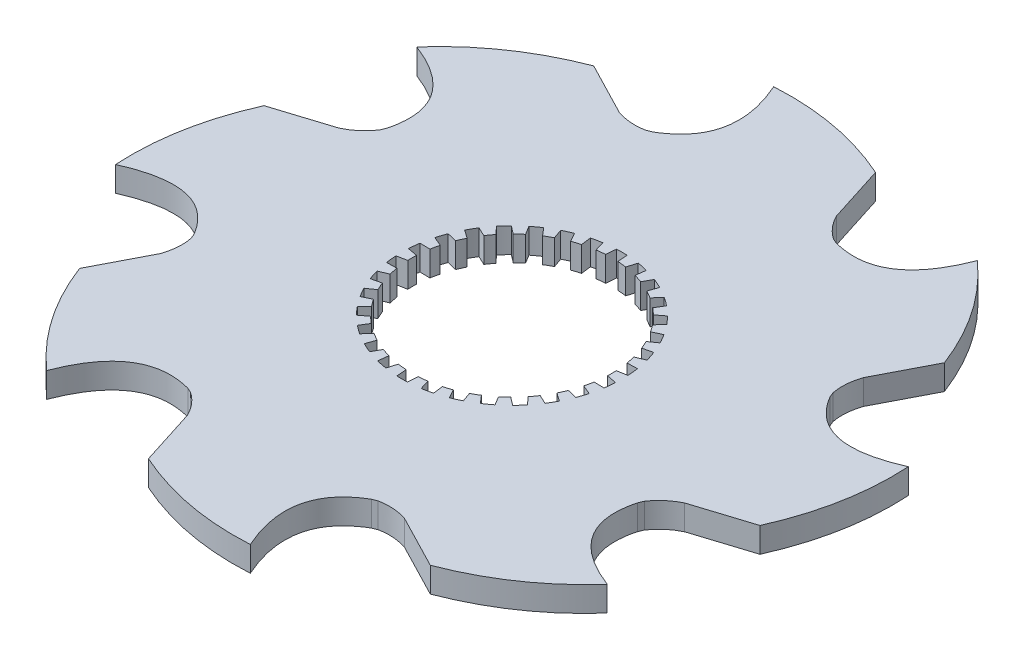
from build123d import *

# Parameters (mm, degrees)
BOSS_EXTRUDE3_DEPTH = 5.291666667
SCALE1_SCALE        = 0.6
CUT_EXTRUDE1_DEPTH  = 4.175000111


with BuildPart() as part:
    # Sketch1 → Boss-Extrude3 (new body)
    with BuildSketch(Plane(origin=(0, 0, 0), x_dir=(1, 0, 0), z_dir=(0, 1, 0))):
        with BuildLine():
            Line((16.082815792, 52.643330727), (12.234245597, 64.746161282))
            add(Edge.make_bspline(
                [(12.234245597, 64.746161282), (-0.632453328, 70.485640077), (-14.259982208, 69.675729687)],
                knots=[0, 0, 0, 1, 1, 1], degree=2))
            add(Edge.make_bspline(
                [(-14.259982208, 69.675729687), (-7.688825446, 54.974319587), (-18.823795668, 48.548425481)],
                knots=[0, 0, 0, 1, 1, 1], degree=2))
            ThreePointArc((-18.823795668, 48.548425481), (-19.32325851, 48.351800179), (-19.820667894, 48.150036596))
            add(Edge.make_bspline(
                [(-25.852188034, 48.596724248), (-22.870362902, 47.559948704), (-19.820667894, 48.150036596)],
                knots=[0, 0, 0, 1, 1, 1], degree=2))
            Line((-25.852188034, 48.596724248), (-37.131531674, 54.433367723))
            add(Edge.make_bspline(
                [(-37.131531674, 54.433367723), (-50.288086112, 49.393662038), (-59.351511065, 39.184850827)],
                knots=[0, 0, 0, 1, 1, 1], degree=2))
            add(Edge.make_bspline(
                [(-59.351511065, 39.184850827), (-44.309534783, 33.435893559), (-47.639354438, 21.018487309)],
                knots=[0, 0, 0, 1, 1, 1], degree=2))
            ThreePointArc((-47.639354438, 21.018487309), (-47.853492916, 20.526278663), (-48.062546067, 20.031888716))
            add(Edge.make_bspline(
                [(-52.643330727, 16.082815792), (-49.801750938, 17.458173545), (-48.062546067, 20.031888716)],
                knots=[0, 0, 0, 1, 1, 1], degree=2))
            Line((-52.643330727, 16.082815792), (-64.746161282, 12.234245597))
            add(Edge.make_bspline(
                [(-64.746161282, 12.234245597), (-70.485640077, -0.632453328), (-69.675729687, -14.259982208)],
                knots=[0, 0, 0, 1, 1, 1], degree=2))
            add(Edge.make_bspline(
                [(-69.675729687, -14.259982208), (-54.974319587, -7.688825446), (-48.548425481, -18.823795668)],
                knots=[0, 0, 0, 1, 1, 1], degree=2))
            ThreePointArc((-48.548425481, -18.823795668), (-48.351800179, -19.32325851), (-48.150036596, -19.820667894))
            add(Edge.make_bspline(
                [(-48.596724248, -25.852188034), (-47.559948704, -22.870362902), (-48.150036596, -19.820667894)],
                knots=[0, 0, 0, 1, 1, 1], degree=2))
            Line((-48.596724248, -25.852188034), (-54.433367723, -37.131531674))
            add(Edge.make_bspline(
                [(-54.433367723, -37.131531674), (-49.393662038, -50.288086112), (-39.184850827, -59.351511065)],
                knots=[0, 0, 0, 1, 1, 1], degree=2))
            add(Edge.make_bspline(
                [(-39.184850827, -59.351511065), (-33.435893559, -44.309534783), (-21.018487309, -47.639354438)],
                knots=[0, 0, 0, 1, 1, 1], degree=2))
            ThreePointArc((-21.018487309, -47.639354438), (-20.526278663, -47.853492916), (-20.031888716, -48.062546067))
            add(Edge.make_bspline(
                [(-16.082815792, -52.643330727), (-17.458173545, -49.801750938), (-20.031888716, -48.062546067)],
                knots=[0, 0, 0, 1, 1, 1], degree=2))
            Line((-16.082815792, -52.643330727), (-12.234245597, -64.746161282))
            add(Edge.make_bspline(
                [(-12.234245597, -64.746161282), (0.632453328, -70.485640077), (14.259982208, -69.675729687)],
                knots=[0, 0, 0, 1, 1, 1], degree=2))
            add(Edge.make_bspline(
                [(14.259982208, -69.675729687), (7.688825446, -54.974319587), (18.823795668, -48.548425481)],
                knots=[0, 0, 0, 1, 1, 1], degree=2))
            ThreePointArc((18.823795668, -48.548425481), (19.32325851, -48.351800179), (19.820667894, -48.150036596))
            add(Edge.make_bspline(
                [(25.852188034, -48.596724248), (22.870362902, -47.559948704), (19.820667894, -48.150036596)],
                knots=[0, 0, 0, 1, 1, 1], degree=2))
            Line((25.852188034, -48.596724248), (37.131531674, -54.433367723))
            add(Edge.make_bspline(
                [(37.131531674, -54.433367723), (50.288086112, -49.393662038), (59.351511065, -39.184850827)],
                knots=[0, 0, 0, 1, 1, 1], degree=2))
            add(Edge.make_bspline(
                [(59.351511065, -39.184850827), (44.309534783, -33.435893559), (47.639354438, -21.018487309)],
                knots=[0, 0, 0, 1, 1, 1], degree=2))
            ThreePointArc((47.639354438, -21.018487309), (47.853492916, -20.526278663), (48.062546067, -20.031888716))
            add(Edge.make_bspline(
                [(52.643330727, -16.082815792), (49.801750938, -17.458173545), (48.062546067, -20.031888716)],
                knots=[0, 0, 0, 1, 1, 1], degree=2))
            Line((52.643330727, -16.082815792), (64.746161282, -12.234245597))
            add(Edge.make_bspline(
                [(64.746161282, -12.234245597), (70.485640077, 0.632453328), (69.675729687, 14.259982208)],
                knots=[0, 0, 0, 1, 1, 1], degree=2))
            add(Edge.make_bspline(
                [(69.675729687, 14.259982208), (54.974319587, 7.688825446), (48.548425481, 18.823795668)],
                knots=[0, 0, 0, 1, 1, 1], degree=2))
            ThreePointArc((48.548425481, 18.823795668), (48.351800179, 19.32325851), (48.150036596, 19.820667894))
            add(Edge.make_bspline(
                [(48.596724248, 25.852188034), (47.559948704, 22.870362902), (48.150036596, 19.820667894)],
                knots=[0, 0, 0, 1, 1, 1], degree=2))
            Line((48.596724248, 25.852188034), (54.433367723, 37.131531674))
            add(Edge.make_bspline(
                [(54.433367723, 37.131531674), (49.393662038, 50.288086112), (39.184850827, 59.351511065)],
                knots=[0, 0, 0, 1, 1, 1], degree=2))
            add(Edge.make_bspline(
                [(39.184850827, 59.351511065), (33.435893559, 44.309534783), (21.018487309, 47.639354438)],
                knots=[0, 0, 0, 1, 1, 1], degree=2))
            ThreePointArc((21.018487309, 47.639354438), (20.526278663, 47.853492916), (20.031888716, 48.062546067))
            add(Edge.make_bspline(
                [(16.082815792, 52.643330727), (17.458173545, 49.801750938), (20.031888716, 48.062546067)],
                knots=[0, 0, 0, 1, 1, 1], degree=2))
        make_face()
    extrude(amount=BOSS_EXTRUDE3_DEPTH)


with BuildPart() as part_1:
    # Scale1: scaled about (0, 2.645833333, 0)
    add(part.part.scale(SCALE1_SCALE).moved(Location((0, 1.058333333, 0))))

    # Sketch9 → Cut-Extrude1 (cut, through all)
    with BuildSketch(Plane(origin=(0, 4.233333345, 0), x_dir=(1, 0, 0), z_dir=(0, 1, 0))):
        with BuildLine():
            Line((0.670254455, 13.953911959), (0.775316452, 12.67631194))
            ThreePointArc((0.775316452, 12.67631194), (1.327511483, 12.630428071), (1.877179521, 12.560501465))
            Line((1.877179521, 12.560501465), (2.245573641, 13.788339241))
            ThreePointArc((2.245573641, 13.788339241), (2.904526321, 13.664721982), (3.556789216, 13.509631767))
            Line((3.556789216, 13.509631767), (3.393927376, 12.238106756))
            ThreePointArc((3.393927376, 12.238106756), (3.924515829, 12.078417757), (4.447633742, 11.895736803))
            Line((4.447633742, 11.895736803), (5.063259395, 13.020149934))
            ThreePointArc((5.063259395, 13.020149934), (5.682110904, 12.762230043), (6.287875221, 12.474915839))
            Line((6.287875221, 12.474915839), (5.864207388, 11.265037581))
            ThreePointArc((5.864207388, 11.265037581), (6.35, 10.998522628), (6.823705026, 10.711071362))
            Line((6.823705026, 10.711071362), (7.659656416, 11.682917597))
            ThreePointArc((7.659656416, 11.682917597), (8.211359975, 11.301967411), (8.744150906, 10.894986229))
            Line((8.744150906, 10.894986229), (8.078193398, 9.799632209))
            ThreePointArc((8.078193398, 9.799632209), (8.497958701, 9.437939284), (8.901547657, 9.058280704))
            Line((8.901547657, 9.058280704), (9.921289697, 9.835085701))
            ThreePointArc((9.921289697, 9.835085701), (10.381733212, 9.347754571), (10.818265238, 8.83889344))
            Line((10.818265238, 8.83889344), (9.939123592, 7.905935885))
            ThreePointArc((9.939123592, 7.905935885), (10.274515829, 7.464872704), (10.59034994, 7.009599713))
            Line((10.59034994, 7.009599713), (11.749315011, 7.557413365))
            ThreePointArc((11.749315011, 7.557413365), (12.098374891, 6.985), (12.419569467, 6.396498594))
            Line((12.419569467, 6.396498594), (11.365666392, 5.666712226))
            ThreePointArc((11.365666392, 5.666712226), (11.602027312, 5.165555367), (11.816303113, 4.654565579))
            Line((11.816303113, 4.654565579), (13.063838879, 4.949445801))
            ThreePointArc((13.063838879, 4.949445801), (13.286259533, 4.316967411), (13.478078914, 3.674546066))
            Line((13.478078914, 3.674546066), (12.295475033, 3.179826051))
            ThreePointArc((12.295475033, 3.179826051), (12.422474529, 2.640478473), (12.52582714, 2.096104594))
            Line((12.52582714, 2.096104594), (13.807410301, 2.125163705))
            ThreePointArc((13.807410301, 2.125163705), (13.893470878, 1.460262632), (13.947531638, 0.791998242))
            Line((13.947531638, 0.791998242), (12.687912414, 0.55396622))
            ThreePointArc((12.687912414, 0.55396622), (12.7, 0), (12.687912414, -0.55396622))
            Line((12.687912414, -0.55396622), (13.947531638, -0.791998242))
            ThreePointArc((13.947531638, -0.791998242), (13.893470878, -1.460262632), (13.807410301, -2.125163705))
            Line((13.807410301, -2.125163705), (12.52582714, -2.096104594))
            ThreePointArc((12.52582714, -2.096104594), (12.422474529, -2.640478473), (12.295475033, -3.179826051))
            Line((12.295475033, -3.179826051), (13.478078914, -3.674546066))
            ThreePointArc((13.478078914, -3.674546066), (13.286259533, -4.316967411), (13.063838879, -4.949445801))
            Line((13.063838879, -4.949445801), (11.816303113, -4.654565579))
            ThreePointArc((11.816303113, -4.654565579), (11.602027312, -5.165555367), (11.365666392, -5.666712226))
            Line((11.365666392, -5.666712226), (12.419569467, -6.396498594))
            ThreePointArc((12.419569467, -6.396498594), (12.098374891, -6.985), (11.749315011, -7.557413365))
            Line((11.749315011, -7.557413365), (10.59034994, -7.009599713))
            ThreePointArc((10.59034994, -7.009599713), (10.274515829, -7.464872704), (9.939123592, -7.905935885))
            Line((9.939123592, -7.905935885), (10.818265238, -8.83889344))
            ThreePointArc((10.818265238, -8.83889344), (10.381733212, -9.347754571), (9.921289697, -9.835085701))
            Line((9.921289697, -9.835085701), (8.901547657, -9.058280704))
            ThreePointArc((8.901547657, -9.058280704), (8.497958701, -9.437939284), (8.078193398, -9.799632209))
            Line((8.078193398, -9.799632209), (8.744150906, -10.894986229))
            ThreePointArc((8.744150906, -10.894986229), (8.211359975, -11.301967411), (7.659656416, -11.682917597))
            Line((7.659656416, -11.682917597), (6.823705026, -10.711071362))
            ThreePointArc((6.823705026, -10.711071362), (6.35, -10.998522628), (5.864207388, -11.265037581))
            Line((5.864207388, -11.265037581), (6.287875221, -12.474915839))
            ThreePointArc((6.287875221, -12.474915839), (5.682110904, -12.762230043), (5.063259395, -13.020149934))
            Line((5.063259395, -13.020149934), (4.447633742, -11.895736803))
            ThreePointArc((4.447633742, -11.895736803), (3.924515829, -12.078417757), (3.393927376, -12.238106756))
            Line((3.393927376, -12.238106756), (3.556789216, -13.509631767))
            ThreePointArc((3.556789216, -13.509631767), (2.904526321, -13.664721982), (2.245573641, -13.788339241))
            Line((2.245573641, -13.788339241), (1.877179521, -12.560501465))
            ThreePointArc((1.877179521, -12.560501465), (1.327511483, -12.630428071), (0.775316452, -12.67631194))
            Line((0.775316452, -12.67631194), (0.670254455, -13.953911959))
            ThreePointArc((0.670254455, -13.953911959), (0, -13.97), (-0.670254455, -13.953911959))
            Line((-0.670254455, -13.953911959), (-0.775316452, -12.67631194))
            ThreePointArc((-0.775316452, -12.67631194), (-1.327511483, -12.630428071), (-1.877179521, -12.560501465))
            Line((-1.877179521, -12.560501465), (-2.245573641, -13.788339241))
            ThreePointArc((-2.245573641, -13.788339241), (-2.904526321, -13.664721982), (-3.556789216, -13.509631767))
            Line((-3.556789216, -13.509631767), (-3.393927376, -12.238106756))
            ThreePointArc((-3.393927376, -12.238106756), (-3.924515829, -12.078417757), (-4.447633742, -11.895736803))
            Line((-4.447633742, -11.895736803), (-5.063259395, -13.020149934))
            ThreePointArc((-5.063259395, -13.020149934), (-5.682110904, -12.762230043), (-6.287875221, -12.474915839))
            Line((-6.287875221, -12.474915839), (-5.864207388, -11.265037581))
            ThreePointArc((-5.864207388, -11.265037581), (-6.35, -10.998522628), (-6.823705026, -10.711071362))
            Line((-6.823705026, -10.711071362), (-7.659656416, -11.682917597))
            ThreePointArc((-7.659656416, -11.682917597), (-8.211359975, -11.301967411), (-8.744150906, -10.894986229))
            Line((-8.744150906, -10.894986229), (-8.078193398, -9.799632209))
            ThreePointArc((-8.078193398, -9.799632209), (-8.497958701, -9.437939284), (-8.901547657, -9.058280704))
            Line((-8.901547657, -9.058280704), (-9.921289697, -9.835085701))
            ThreePointArc((-9.921289697, -9.835085701), (-10.381733212, -9.347754571), (-10.818265238, -8.83889344))
            Line((-10.818265238, -8.83889344), (-9.939123592, -7.905935885))
            ThreePointArc((-9.939123592, -7.905935885), (-10.274515829, -7.464872704), (-10.59034994, -7.009599713))
            Line((-10.59034994, -7.009599713), (-11.749315011, -7.557413365))
            ThreePointArc((-11.749315011, -7.557413365), (-12.098374891, -6.985), (-12.419569467, -6.396498594))
            Line((-12.419569467, -6.396498594), (-11.365666392, -5.666712226))
            ThreePointArc((-11.365666392, -5.666712226), (-11.602027312, -5.165555367), (-11.816303113, -4.654565579))
            Line((-11.816303113, -4.654565579), (-13.063838879, -4.949445801))
            ThreePointArc((-13.063838879, -4.949445801), (-13.286259533, -4.316967411), (-13.478078914, -3.674546066))
            Line((-13.478078914, -3.674546066), (-12.295475033, -3.179826051))
            ThreePointArc((-12.295475033, -3.179826051), (-12.422474529, -2.640478473), (-12.52582714, -2.096104594))
            Line((-12.52582714, -2.096104594), (-13.807410301, -2.125163705))
            ThreePointArc((-13.807410301, -2.125163705), (-13.893470878, -1.460262632), (-13.947531638, -0.791998242))
            Line((-13.947531638, -0.791998242), (-12.687912414, -0.55396622))
            ThreePointArc((-12.687912414, -0.55396622), (-12.7, 0), (-12.687912414, 0.55396622))
            Line((-12.687912414, 0.55396622), (-13.947531638, 0.791998242))
            ThreePointArc((-13.947531638, 0.791998242), (-13.893470878, 1.460262632), (-13.807410301, 2.125163705))
            Line((-13.807410301, 2.125163705), (-12.52582714, 2.096104594))
            ThreePointArc((-12.52582714, 2.096104594), (-12.422474529, 2.640478473), (-12.295475033, 3.179826051))
            Line((-12.295475033, 3.179826051), (-13.478078914, 3.674546066))
            ThreePointArc((-13.478078914, 3.674546066), (-13.286259533, 4.316967411), (-13.063838879, 4.949445801))
            Line((-13.063838879, 4.949445801), (-11.816303113, 4.654565579))
            ThreePointArc((-11.816303113, 4.654565579), (-11.602027312, 5.165555367), (-11.365666392, 5.666712226))
            Line((-11.365666392, 5.666712226), (-12.419569467, 6.396498594))
            ThreePointArc((-12.419569467, 6.396498594), (-12.098374891, 6.985), (-11.749315011, 7.557413365))
            Line((-11.749315011, 7.557413365), (-10.59034994, 7.009599713))
            ThreePointArc((-10.59034994, 7.009599713), (-10.274515829, 7.464872704), (-9.939123592, 7.905935885))
            Line((-9.939123592, 7.905935885), (-10.818265238, 8.83889344))
            ThreePointArc((-10.818265238, 8.83889344), (-10.381733212, 9.347754571), (-9.921289697, 9.835085701))
            Line((-9.921289697, 9.835085701), (-8.901547657, 9.058280704))
            ThreePointArc((-8.901547657, 9.058280704), (-8.497958701, 9.437939284), (-8.078193398, 9.799632209))
            Line((-8.078193398, 9.799632209), (-8.744150906, 10.894986229))
            ThreePointArc((-8.744150906, 10.894986229), (-8.211359975, 11.301967411), (-7.659656416, 11.682917597))
            Line((-7.659656416, 11.682917597), (-6.823705026, 10.711071362))
            ThreePointArc((-6.823705026, 10.711071362), (-6.35, 10.998522628), (-5.864207388, 11.265037581))
            Line((-5.864207388, 11.265037581), (-6.287875221, 12.474915839))
            ThreePointArc((-6.287875221, 12.474915839), (-5.682110904, 12.762230043), (-5.063259395, 13.020149934))
            Line((-5.063259395, 13.020149934), (-4.447633742, 11.895736803))
            ThreePointArc((-4.447633742, 11.895736803), (-3.924515829, 12.078417757), (-3.393927376, 12.238106756))
            Line((-3.393927376, 12.238106756), (-3.556789216, 13.509631767))
            ThreePointArc((-3.556789216, 13.509631767), (-2.904526321, 13.664721982), (-2.245573641, 13.788339241))
            Line((-2.245573641, 13.788339241), (-1.877179521, 12.560501465))
            ThreePointArc((-1.877179521, 12.560501465), (-1.327511483, 12.630428071), (-0.775316452, 12.67631194))
            Line((-0.775316452, 12.67631194), (-0.670254455, 13.953911959))
            ThreePointArc((-0.670254455, 13.953911959), (0, 13.97), (0.670254455, 13.953911959))
        make_face()
    extrude(amount=-CUT_EXTRUDE1_DEPTH, mode=Mode.SUBTRACT)


solid = part_1.part
